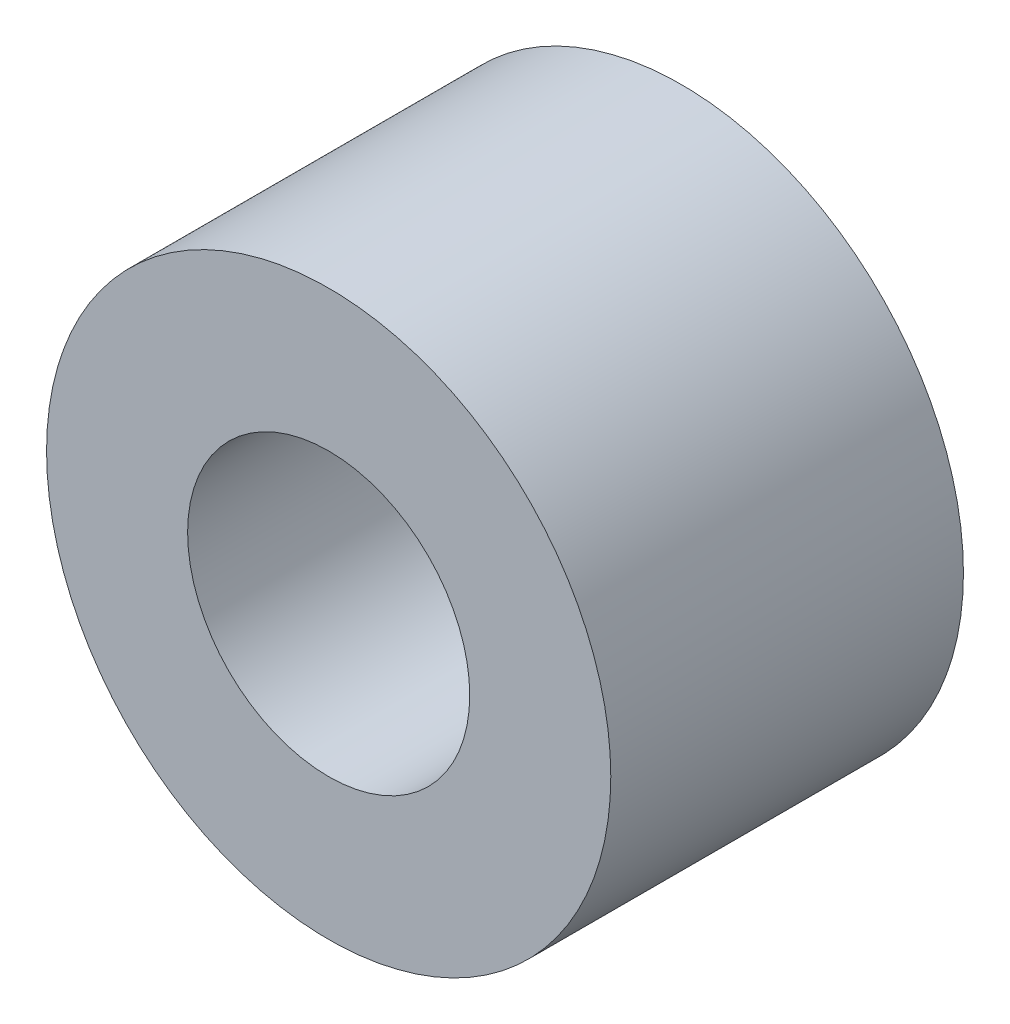
from build123d import *

# Parameters (mm, degrees)
SKETCH1_R           = 4
SKETCH1_R_2         = 2
BOSS_EXTRUDE1_DEPTH = 5


with BuildPart() as part:
    # Sketch1 → Boss-Extrude1 (new body)
    with BuildSketch(Plane.XY):
        with Locations((2.344869011, 1.248075442)):
            Circle(SKETCH1_R)
        with Locations((2.344869011, 1.248075442)):
            Circle(SKETCH1_R_2, mode=Mode.SUBTRACT)
    extrude(amount=BOSS_EXTRUDE1_DEPTH)


solid = part.part
